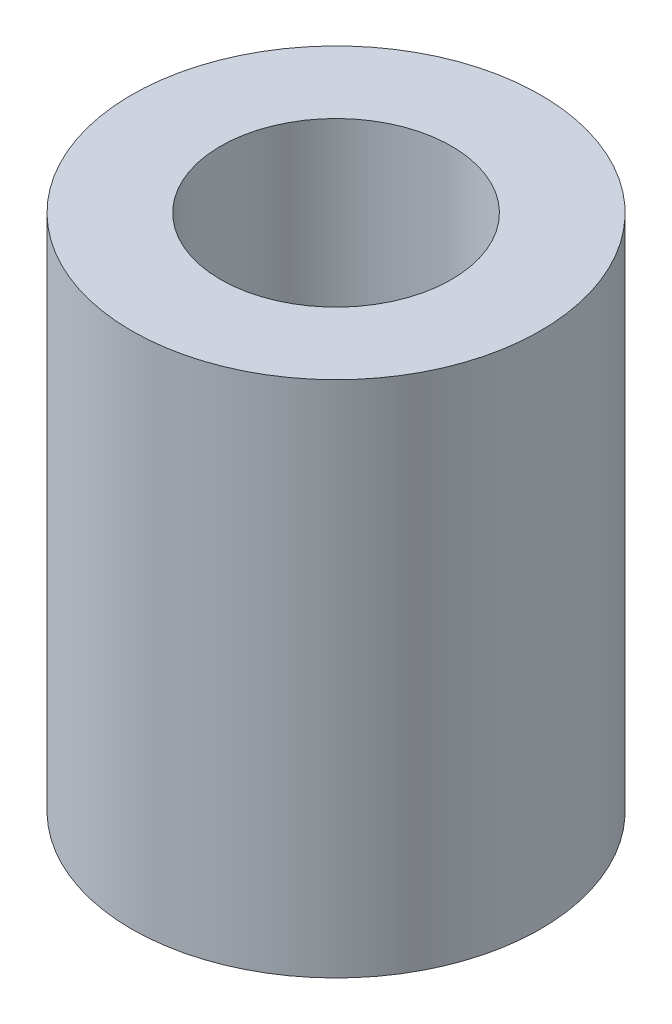
from build123d import *

# Parameters (mm, degrees)
SKETCH1_R           = 5.842
SKETCH1_R_2         = 3.302
BOSS_EXTRUDE1_DEPTH = 14.8082


with BuildPart() as part:
    # Sketch1 → Boss-Extrude1 (new body)
    with BuildSketch(Plane(origin=(0, 0, 0), x_dir=(1, 0, 0), z_dir=(0, 1, 0))):
        Circle(SKETCH1_R)
        Circle(SKETCH1_R_2, mode=Mode.SUBTRACT)
    extrude(amount=BOSS_EXTRUDE1_DEPTH)


solid = part.part
